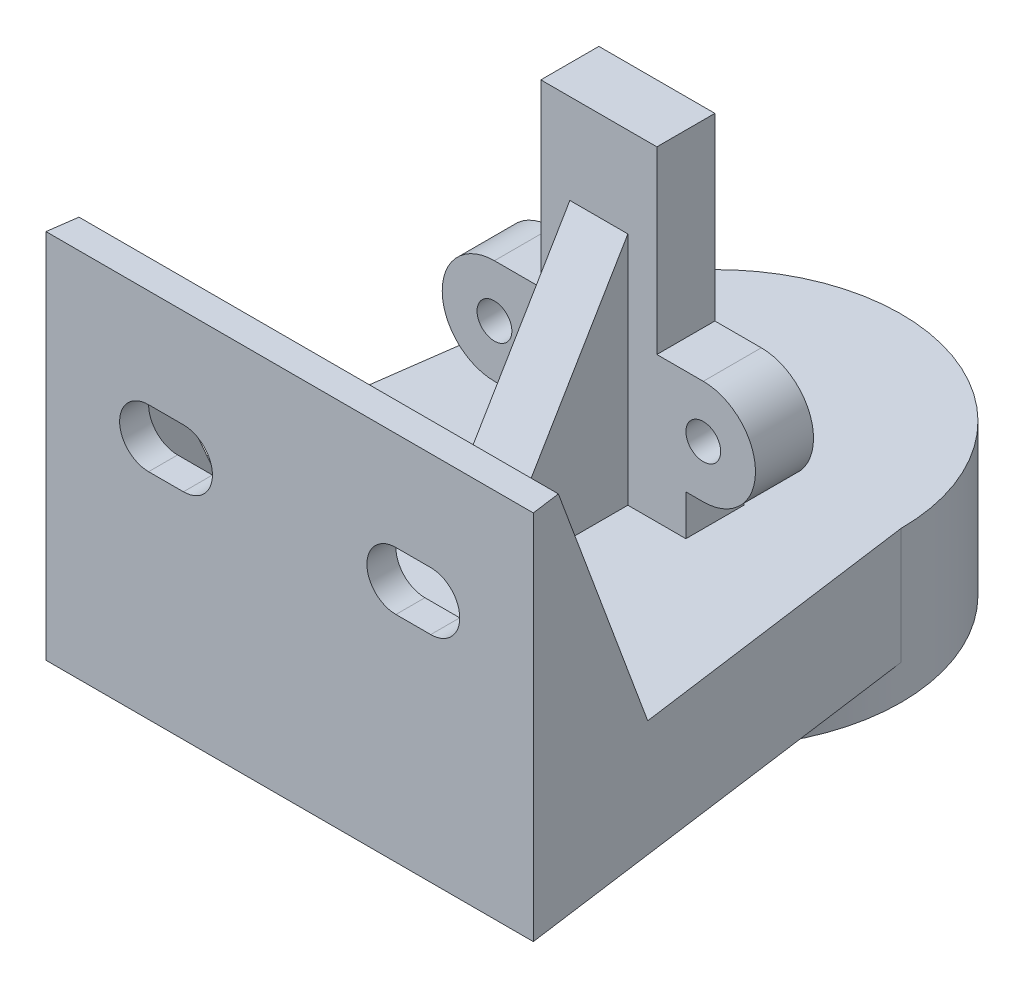
from build123d import *

# Parameters (mm, degrees)
SKETCH1_R            = 16
BOSS_EXTRUDE1_DEPTH  = 13
SKETCH2_R            = 12.55
CUT_EXTRUDE1_DEPTH   = 8
SKETCH3_R            = 4.05
CUT_EXTRUDE2_DEPTH   = 5
SKETCH4_W            = 15
SKETCH4_H            = 5
BOSS_EXTRUDE2_DEPTH  = 28
BOSS_EXTRUDE5_DEPTH  = 5
SKETCH7_R            = 1.5
SKETCH7_W            = 2.5
SKETCH7_H            = 15.5
CUT_EXTRUDE3_DEPTH   = 5
BOSS_EXTRUDE6_DEPTH  = 10
BOSS_EXTRUDE7_DEPTH  = 22
CUT_EXTRUDE5_DEPTH   = 2.5
BOSS_EXTRUDE8_DEPTH  = 2
BOSS_EXTRUDE9_DEPTH  = 2
SKETCH14_W           = 5
SKETCH14_H           = 20.25
BOSS_EXTRUDE10_DEPTH = 12
CUT_EXTRUDE6_DEPTH   = 5


with BuildPart() as part:
    # Sketch1 → Boss-Extrude1 (new body)
    with BuildSketch(Plane(origin=(0, 0, 0), x_dir=(1, 0, 0), z_dir=(0, 1, 0))):
        Circle(SKETCH1_R)
    extrude(amount=BOSS_EXTRUDE1_DEPTH)

    # Sketch2 → Cut-Extrude1 (cut)
    with BuildSketch(Plane.XZ):
        Circle(SKETCH2_R)
    extrude(amount=-CUT_EXTRUDE1_DEPTH, mode=Mode.SUBTRACT)

    # Sketch3 → Cut-Extrude2 (cut)
    with BuildSketch(Plane(origin=(0, 13, 0), x_dir=(1, 0, 0), z_dir=(0, 1, 0))):
        Circle(SKETCH3_R)
    extrude(amount=-CUT_EXTRUDE2_DEPTH, mode=Mode.SUBTRACT)

    # Sketch4 → Boss-Extrude2 (add)
    with BuildSketch(Plane(origin=(0, 13, 0), x_dir=(1, 0, 0), z_dir=(0, 1, 0))):
        with Locations((0, -7.55)):
            Rectangle(SKETCH4_W, SKETCH4_H)
    extrude(amount=BOSS_EXTRUDE2_DEPTH)

    # Sketch6 → Boss-Extrude5 (add)
    with BuildSketch(Plane(origin=(0, 0, 5.05), x_dir=(-1, 0, 0), z_dir=(0, 0, -1))):
        with BuildLine():
            Line((7.5, 16.5), (9, 16.5))
            ThreePointArc((9, 16.5), (13.5, 21), (9, 25.5))
            Line((9, 25.5), (7.5, 25.5))
            Line((7.5, 25.5), (7.5, 16.5))
        make_face()
        with BuildLine():
            Line((-7.5, 16.5), (-9, 16.5))
            ThreePointArc((-9, 16.5), (-13.5, 21), (-9, 25.5))
            Line((-9, 25.5), (-7.5, 25.5))
            Line((-7.5, 25.5), (-7.5, 16.5))
        make_face()
    extrude(amount=-BOSS_EXTRUDE5_DEPTH)

    # Sketch7 → Cut-Extrude3 (cut)
    with BuildSketch(Plane(origin=(0, 0, 5.05), x_dir=(-1, 0, 0), z_dir=(0, 0, -1))):
        with Locations((-9, 21)):
            Circle(SKETCH7_R)
        with Locations((9, 21)):
            Circle(SKETCH7_R)
        with Locations((6.25, 33.25)):
            Rectangle(SKETCH7_W, SKETCH7_H)
        with Locations((-6.25, 33.25)):
            Rectangle(SKETCH7_W, SKETCH7_H)
    extrude(amount=-CUT_EXTRUDE3_DEPTH, mode=Mode.SUBTRACT)

    # Sketch8 → Boss-Extrude6 (add)
    with BuildSketch(Plane(origin=(0, 13, 0), x_dir=(1, 0, 0), z_dir=(0, 1, 0))):
        with BuildLine():
            Line((-21, -36.7), (21, -36.7))
            Line((21, -36.7), (16, 0))
            ThreePointArc((16, 0), (0.171359704, -15.999082344), (-15.996329481, -0.342699752))
            Line((-15.996329481, -0.342699752), (-21, -36.7))
        make_face()
    extrude(amount=-BOSS_EXTRUDE6_DEPTH)

    # Sketch9 → Boss-Extrude7 (add)
    with BuildSketch(Plane(origin=(0, 13, 0), x_dir=(1, 0, 0), z_dir=(0, 1, 0))):
        Polygon((-21, -36.7), (21, -36.7), (20.659400545, -34.2), (-20.655937701, -34.2), align=None)
    extrude(amount=BOSS_EXTRUDE7_DEPTH)

    # Sketch11 → Cut-Extrude5 (cut)
    with BuildSketch(Plane(origin=(0, 0, 34.2), x_dir=(-1, 0, 0), z_dir=(0, 0, -1))):
        with BuildLine():
            Line((12.155937701, 21.5), (9.155937701, 21.5))
            ThreePointArc((9.155937701, 21.5), (6.655937701, 24), (9.155937701, 26.5))
            Line((9.155937701, 26.5), (12.155937701, 26.5))
            ThreePointArc((12.155937701, 26.5), (14.655937701, 24), (12.155937701, 21.5))
        make_face()
        with BuildLine():
            Line((-9.159400545, 21.5), (-12.159400545, 21.5))
            ThreePointArc((-12.159400545, 21.5), (-14.659400545, 24), (-12.159400545, 26.5))
            Line((-12.159400545, 26.5), (-9.159400545, 26.5))
            ThreePointArc((-9.159400545, 26.5), (-6.659400545, 24), (-9.159400545, 21.5))
        make_face()
    extrude(amount=-CUT_EXTRUDE5_DEPTH, mode=Mode.SUBTRACT)

    # Sketch13 → Boss-Extrude9 (add)
    with BuildSketch(Plane(origin=(15.708431434, 0, -2.140113274), x_dir=(-0.134992723, 0, -0.99084659), z_dir=(0.99084659, 0, -0.134992723))):
        Polygon((-36.675822117, 13), (-27.675822117, 13), (-36.675822117, 35), align=None)
    extrude(amount=-BOSS_EXTRUDE9_DEPTH)

    # Sketch14 → Boss-Extrude10 (add)
    with BuildSketch(Plane.XY.offset(10.05)):
        with Locations((0, 23.125)):
            Rectangle(SKETCH14_W, SKETCH14_H)
    extrude(amount=BOSS_EXTRUDE10_DEPTH)

    # Sketch15 → Cut-Extrude6 (cut)
    with BuildSketch(Plane.ZY.offset(2.5)):
        Polygon((10.05, 33.25), (22.05, 13), (22.05, 33.25), align=None)
    extrude(amount=-CUT_EXTRUDE6_DEPTH, mode=Mode.SUBTRACT)


with BuildPart() as body_2:
    # Sketch12 → Boss-Extrude8 (new body)
    with BuildSketch(Plane(origin=(-15.652693756, 0, -2.154200717), x_dir=(-0.136339796, 0, 0.990662132), z_dir=(-0.990662132, 0, -0.136339796))):
        Polygon((36.696871253, 13), (27.696871253, 13), (36.696871253, 35), align=None)
    extrude(amount=-BOSS_EXTRUDE8_DEPTH)


solid = Compound([part.part, body_2.part])
